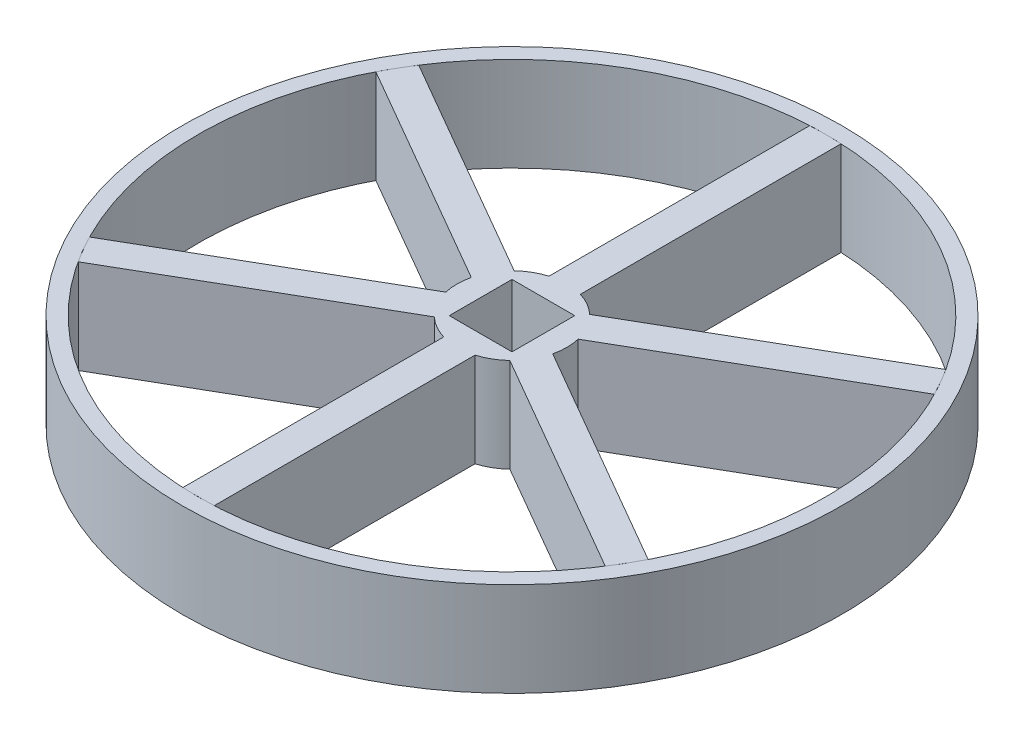
from build123d import *

# Parameters (mm, degrees)
SKETCH1_R           = 21
SKETCH1_R_2         = 20
BOSS_EXTRUDE4_DEPTH = 6
BOSS_EXTRUDE5_DEPTH = 6
SKETCH5_W           = 4
SKETCH5_H           = 4
CUT_EXTRUDE1_DEPTH  = 15


with BuildPart() as part:
    # Sketch1 → Boss-Extrude4 (new body)
    with BuildSketch(Plane(origin=(0, 0, 0), x_dir=(1, 0, 0), z_dir=(0, 1, 0))):
        Circle(SKETCH1_R)
        Circle(SKETCH1_R_2, mode=Mode.SUBTRACT)
    extrude(amount=BOSS_EXTRUDE4_DEPTH)


with BuildPart() as body_2:
    # Sketch4 → Boss-Extrude5 (new body)
    with BuildSketch(Plane(origin=(0, 0, 0), x_dir=(1, 0, 0), z_dir=(0, 1, 0))):
        with BuildLine():
            ThreePointArc((1, -3.354101966), (1.75, -3.031088913), (2.40473751, -2.543076387))
            Line((2.40473751, -2.543076387), (16.793084245, -10.850192248))
            ThreePointArc((16.793084245, -10.850192248), (17.314755635, -9.996678827), (17.793084245, -9.11814144))
            Line((17.793084245, -9.11814144), (3.40473751, -0.811025579))
            ThreePointArc((3.40473751, -0.811025579), (3.5, 0), (3.40473751, 0.811025579))
            Line((3.40473751, 0.811025579), (17.793084245, 9.11814144))
            ThreePointArc((17.793084245, 9.11814144), (17.314755635, 9.996678827), (16.793084245, 10.850192248))
            Line((16.793084245, 10.850192248), (2.40473751, 2.543076387))
            ThreePointArc((2.40473751, 2.543076387), (1.75, 3.031088913), (1, 3.354101966))
            Line((1, 3.354101966), (1, 19.968333688))
            ThreePointArc((1, 19.968333688), (0, 19.993357654), (-1, 19.968333688))
            Line((-1, 19.968333688), (-1, 3.354101966))
            ThreePointArc((-1, 3.354101966), (-1.75, 3.031088913), (-2.40473751, 2.543076387))
            Line((-2.40473751, 2.543076387), (-16.793084245, 10.850192248))
            ThreePointArc((-16.793084245, 10.850192248), (-17.314755635, 9.996678827), (-17.793084245, 9.11814144))
            Line((-17.793084245, 9.11814144), (-3.40473751, 0.811025579))
            ThreePointArc((-3.40473751, 0.811025579), (-3.5, 0), (-3.40473751, -0.811025579))
            Line((-3.40473751, -0.811025579), (-17.793084245, -9.11814144))
            ThreePointArc((-17.793084245, -9.11814144), (-17.314755635, -9.996678827), (-16.793084245, -10.850192248))
            Line((-16.793084245, -10.850192248), (-2.40473751, -2.543076387))
            ThreePointArc((-2.40473751, -2.543076387), (-1.75, -3.031088913), (-1, -3.354101966))
            Line((-1, -3.354101966), (-1, -19.968333688))
            ThreePointArc((-1, -19.968333688), (0, -19.993357654), (1, -19.968333688))
            Line((1, -19.968333688), (1, -3.354101966))
        make_face()
    extrude(amount=BOSS_EXTRUDE5_DEPTH)

    # Sketch5 → Cut-Extrude1 (cut)
    with BuildSketch(Plane(origin=(0, 6, 0), x_dir=(1, 0, 0), z_dir=(0, 1, 0))):
        Rectangle(SKETCH5_W, SKETCH5_H)
    extrude(amount=-CUT_EXTRUDE1_DEPTH, mode=Mode.SUBTRACT)


solid = Compound([part.part, body_2.part])
